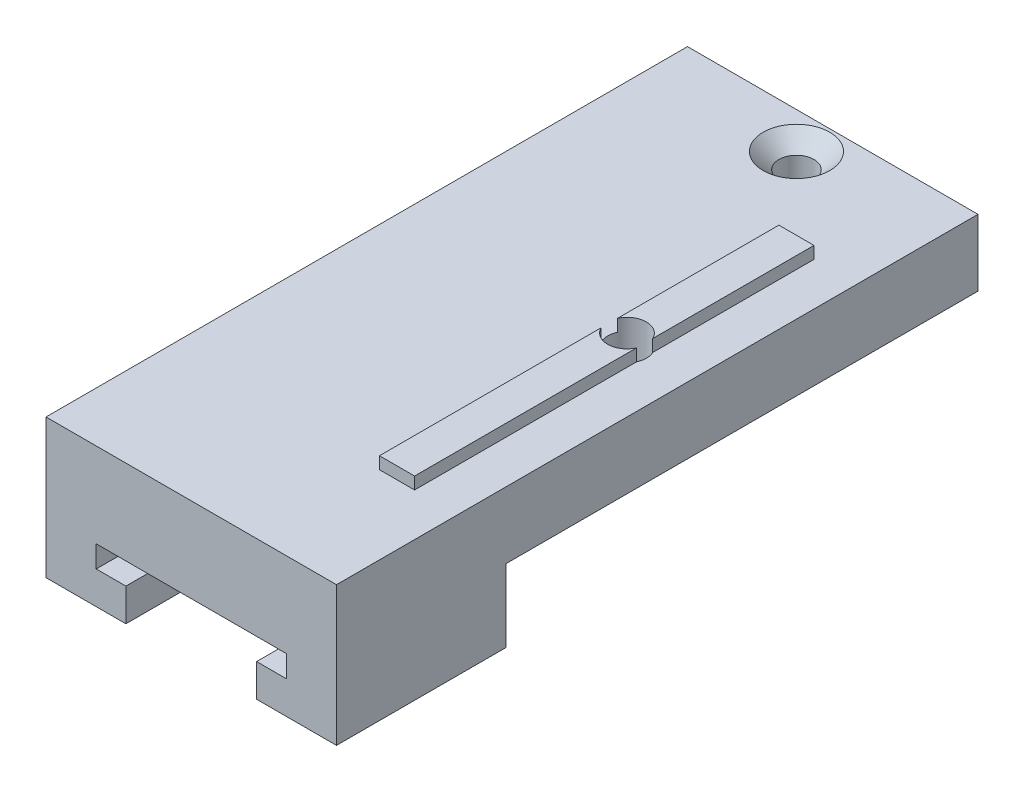
from build123d import *

# Parameters (mm, degrees)
MAIN_DEPTH                                        = 53
SKETCH2_W                                         = 24
SKETCH2_H                                         = 36
CUT_EXTRUDE1_DEPTH                                = 6
SKETCH3_W                                         = 2.9
SKETCH3_H                                         = 33
MAKERBEAMRAIL_DEPTH                               = 1
SKETCH4_R                                         = 1.6
MAKERBEAMHOLE_DEPTH                               = 13.5
SKETCH5_R                                         = 4.35
MAKERBEAMBIGHOLE_DEPTH                            = 3
SKETCH6_W                                         = 15.7
SKETCH6_H                                         = 8.5
PINHOLES_DEPTH                                    = 1.5
CSK_FOR_M2_5_FLAT_HEAD_MACHINE_SCREW1_D           = 2.9
CSK_FOR_M2_5_FLAT_HEAD_MACHINE_SCREW1_CSINK_D     = 5.5
CSK_FOR_M2_5_FLAT_HEAD_MACHINE_SCREW1_CSINK_ANGLE = 90
SKETCH9_W                                         = 6.6
SKETCH9_H                                         = 3
CUT_EXTRUDE5_DEPTH                                = 6


with BuildPart() as part:
    # Sketch1 → Main (new body)
    with BuildSketch(Plane.XY):
        Polygon((12, 0), (5.4, 0), (5.4, 2.7), (7.85, 2.7), (7.85, 4.5), (-7.85, 4.5), (-7.85, 2.7), (-5.4, 2.7), (-5.4, 0), (-12, 0), (-12, 11.5), (12, 11.5), align=None)
    extrude(amount=MAIN_DEPTH)

    # Sketch2 → Cut-Extrude1 (cut)
    with BuildSketch(Plane(origin=(0, 0, 0), x_dir=(1, 0, 0), z_dir=(0, 1, 0))):
        with Locations((0, -18)):
            Rectangle(SKETCH2_W, SKETCH2_H)
    extrude(amount=CUT_EXTRUDE1_DEPTH, mode=Mode.SUBTRACT)

    # Sketch3 → MakerBeamRail (add)
    with BuildSketch(Plane(origin=(0, 11.5, 0), x_dir=(1, 0, 0), z_dir=(0, 1, 0))):
        with Locations((7, -26.5)):
            Rectangle(SKETCH3_W, SKETCH3_H)
    extrude(amount=MAKERBEAMRAIL_DEPTH)

    # Sketch4 → MakerBeamHole (cut, through all)
    with BuildSketch(Plane(origin=(0, 12.5, 0), x_dir=(1, 0, 0), z_dir=(0, 1, 0))):
        with Locations((7, -24)):
            Circle(SKETCH4_R)
    extrude(amount=-MAKERBEAMHOLE_DEPTH, mode=Mode.SUBTRACT)

    # Sketch5 → MakerBeamBigHole (cut)
    with BuildSketch(Plane(origin=(0, 6, 0), x_dir=(-1, 0, 0), z_dir=(0, -1, 0))):
        with Locations((-7, -24)):
            Circle(SKETCH5_R)
    extrude(amount=-MAKERBEAMBIGHOLE_DEPTH, mode=Mode.SUBTRACT)

    # Sketch6 → PinHoles (cut)
    with BuildSketch(Plane.XZ.offset(-4.5)):
        with Locations((0, 40.25)):
            Rectangle(SKETCH6_W, SKETCH6_H)
    extrude(amount=-PINHOLES_DEPTH, mode=Mode.SUBTRACT)

    # CSK for M2.5 Flat Head Machine Screw1 (through all)
    with Locations(Plane(origin=(0, 11.5, 0), x_dir=(1, 0, 0), z_dir=(0, 1, 0))):
        with Locations((0, -3)):
            CounterSinkHole(CSK_FOR_M2_5_FLAT_HEAD_MACHINE_SCREW1_D / 2, CSK_FOR_M2_5_FLAT_HEAD_MACHINE_SCREW1_CSINK_D / 2, counter_sink_angle=CSK_FOR_M2_5_FLAT_HEAD_MACHINE_SCREW1_CSINK_ANGLE)

    # Sketch9 → Cut-Extrude5 (cut)
    with BuildSketch(Plane(origin=(0, 0, 0), x_dir=(-1, 0, 0), z_dir=(0, -1, 0))):
        with Locations((-8.7, -37.5)):
            Rectangle(SKETCH9_W, SKETCH9_H)
    extrude(amount=-CUT_EXTRUDE5_DEPTH, mode=Mode.SUBTRACT)


solid = part.part
